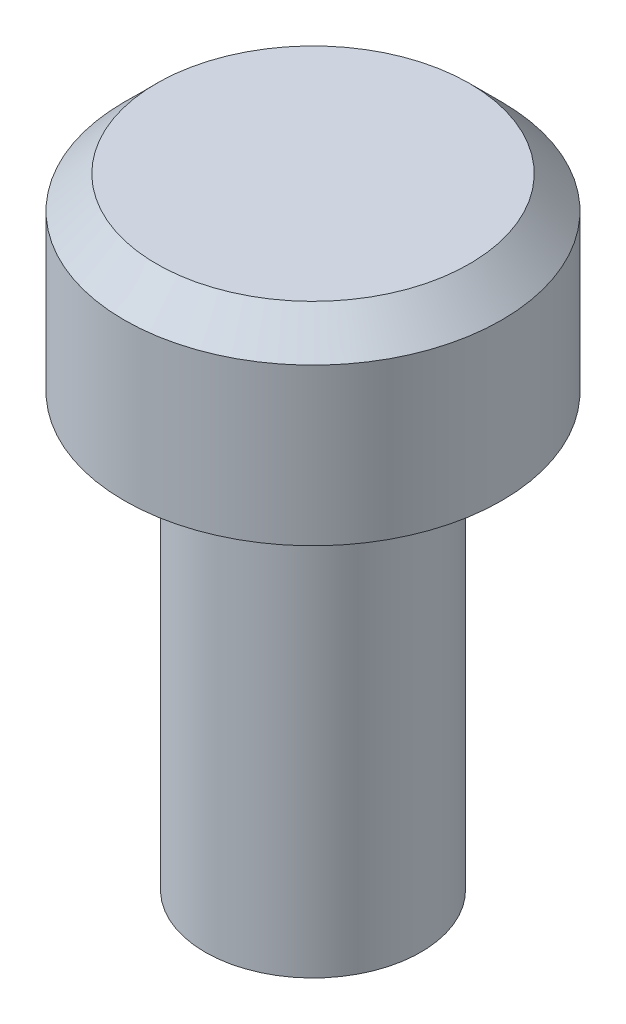
from build123d import *


with BuildPart() as part:
    # Sketch1 → Revolve1 (revolve)
    with BuildSketch(Plane.XY):
        Polygon((-1.45, 1.75), (-1.75, 1.45), (-1.75, 0), (-1, 0), (-1, -4), (0, -4), (0, 1.75), align=None)
    revolve(axis=Axis((0, -4.602690382, 0), (0, 1, 0)))


solid = part.part
